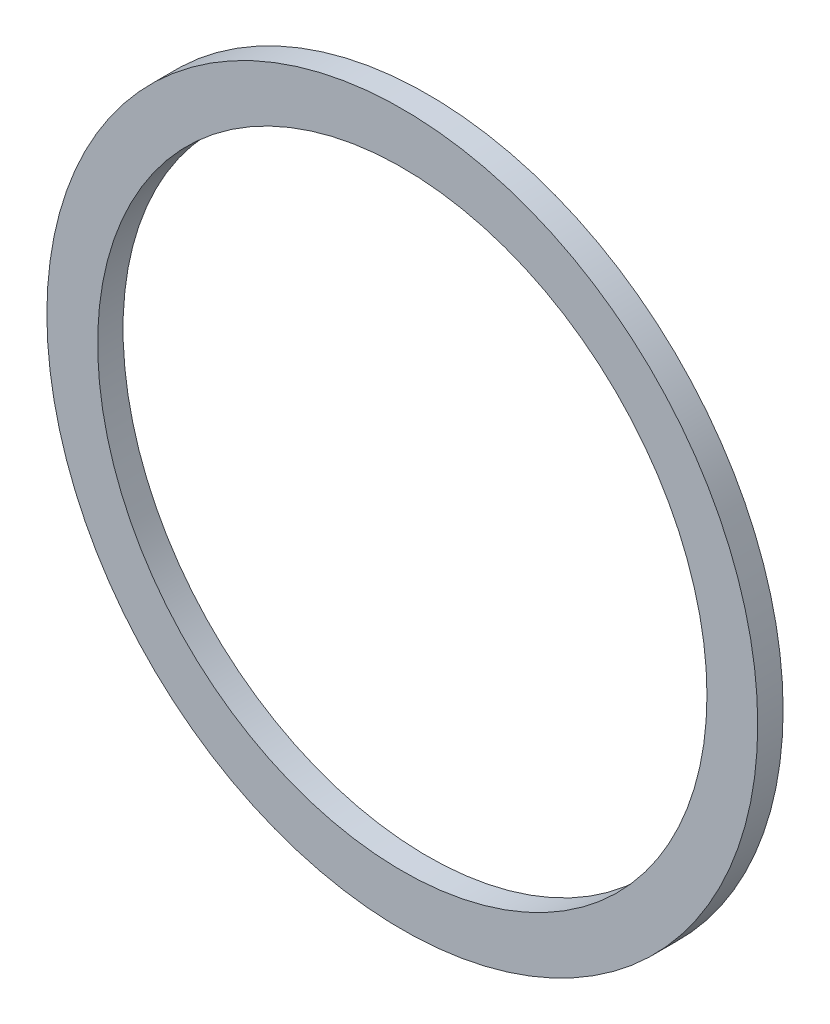
from build123d import *

# Parameters (mm, degrees)
ESQUISSE1_R        = 35
ESQUISSE1_R_2      = 30
BOSS_EXTRU_1_DEPTH = 2.5


with BuildPart() as part:
    # Esquisse1 → Boss.-Extru.1 (new body)
    with BuildSketch(Plane.XY):
        with Locations((-0.099958724, 0.399834896)):
            Circle(ESQUISSE1_R)
        with Locations((-0.099958724, 0.399834896)):
            Circle(ESQUISSE1_R_2, mode=Mode.SUBTRACT)
    extrude(amount=BOSS_EXTRU_1_DEPTH)


solid = part.part
